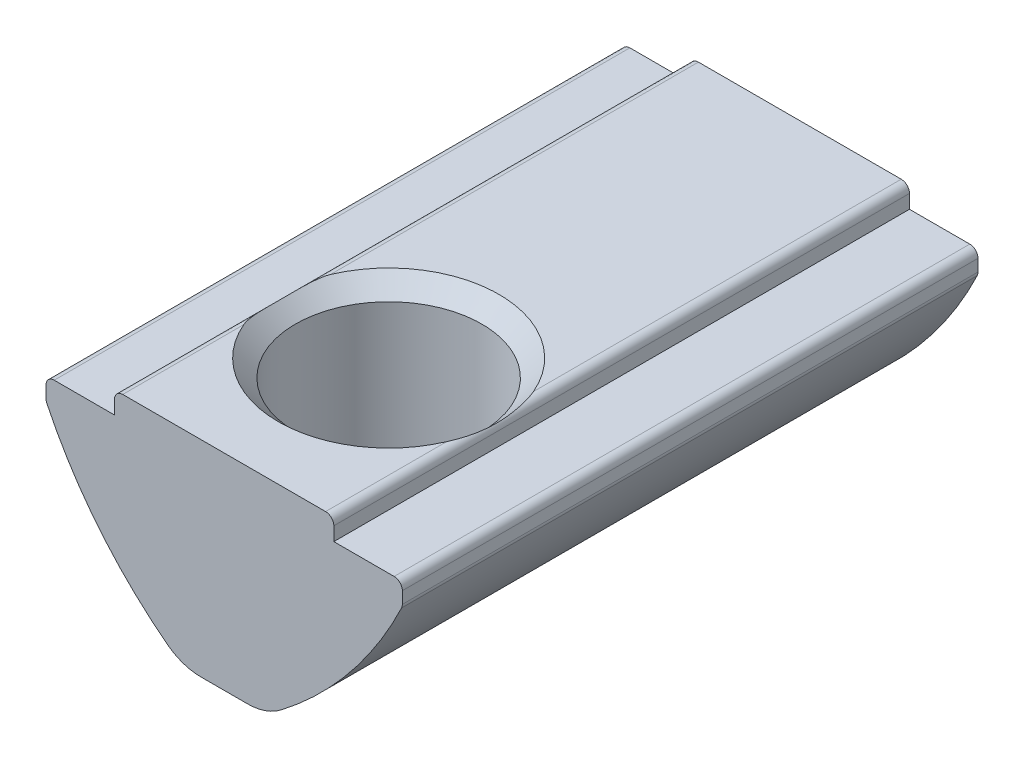
from build123d import *

# Parameters (mm, degrees)
EXTRUDE_1_DEPTH             = 10.5
FILLET_1_R                  = 0.3
FILLET_2_R                  = 2
HOLE_WIZARD_M82_D           = 6.8
HOLE_WIZARD_M82_CSINK_D     = 8.05
HOLE_WIZARD_M82_CSINK_ANGLE = 90


with BuildPart() as part:
    # Эскиз1 → Бобышка-Вытянуть1 (new body, symmetric)
    with BuildSketch(Plane.XY):
        with BuildLine():
            Line((-4, 0), (4, 0))
            Line((4, 0), (4, -0.8))
            Line((4, -0.8), (6.5, -0.8))
            Line((6.5, -0.8), (6.5, -1.6))
            ThreePointArc((6.5, -1.6), (4.386776199, -4.87777644), (1.5, -7.5))
            Line((1.5, -7.5), (-1.5, -7.5))
            ThreePointArc((-1.5, -7.5), (-4.386776199, -4.87777644), (-6.5, -1.6))
            Line((-6.5, -1.6), (-6.5, -0.8))
            Line((-6.5, -0.8), (-4, -0.8))
            Line((-4, -0.8), (-4, 0))
        make_face()
    extrude(amount=EXTRUDE_1_DEPTH, both=True)

    # Скругление1
    fillet_1_edges = [part.edges().sort_by_distance(p)[0] for p in [
        (6.5, -0.8, 0),
        (6.5, -1.6, 0),
        (-6.5, -1.6, 0),
        (-6.5, -0.8, 0),
        (-4, 0, 0),
        (4, 0, 0),
    ]]
    fillet(fillet_1_edges, radius=FILLET_1_R)

    # Скругление2
    fillet_2_edges = [part.edges().sort_by_distance(p)[0] for p in [
        (1.5, -7.5, 0),
        (-1.5, -7.5, 0),
    ]]
    fillet(fillet_2_edges, radius=FILLET_2_R)

    # Отверстие обработанное метчиком M82 (through all)
    with Locations(Plane(origin=(0, 0, 0), x_dir=(1, 0, 0), z_dir=(0, 1, 0))):
        with Locations((0, -4.5)):
            CounterSinkHole(HOLE_WIZARD_M82_D / 2, HOLE_WIZARD_M82_CSINK_D / 2, counter_sink_angle=HOLE_WIZARD_M82_CSINK_ANGLE)

    # Эскиз5 → Повернуть1 (revolve)
    with BuildSketch(Plane(origin=(0, 0, 0), x_dir=(0, 0, -1), z_dir=(1, 0, 0))):
        with BuildLine():
            Line((6.5, -4.3), (6.5, -8.3))
            ThreePointArc((6.5, -8.3), (4.5, -6.3), (6.5, -4.3))
        make_face()
    revolve(axis=Axis((0, -4.3, -6.5), (0, -1, 0)))


solid = part.part
